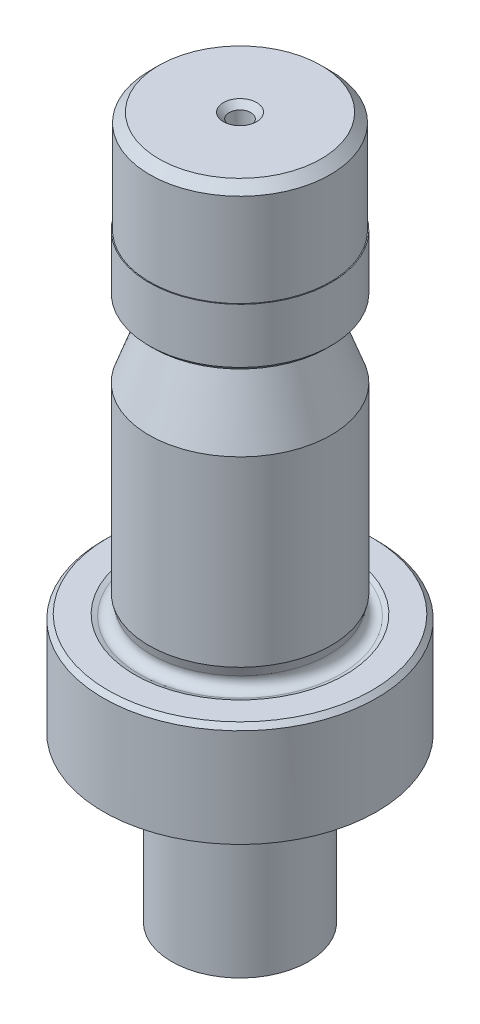
from build123d import *

# Parameters (mm, degrees)
FURO_DE_DI_METRO_3_32_0_09375_2_D           = 2.38125
FURO_DE_DI_METRO_3_32_0_09375_2_DEPTH       = 3
FURO_DE_DI_METRO_3_32_0_09375_2_CSINK_D     = 3.65125
FURO_DE_DI_METRO_3_32_0_09375_2_CSINK_ANGLE = 90
FURO_DE_DI_METRO_3_32_0_09375_2_TIP         = 0.715399675
ESBO_O10_OUTSIDE_W                          = 49.582
ESBO_O10_OUTSIDE_H                          = 49.582
ESBO_O10_OUTSIDE_R                          = 7.5
CORTE_EXTRUS_O2_DEPTH                       = 18
FILETE1_R                                   = 3


with BuildPart() as part:
    # Esboço1 → Revolução1 (revolve)
    with BuildSketch(Plane.XY):
        with BuildLine():
            Line((0, 77), (8.9, 77))
            Line((8.9, 77), (9.9, 76))
            Line((9.9, 76), (9.9, 65.8))
            Line((9.9, 65.8), (10, 65.8))
            Line((10, 65.8), (10, 59.8))
            Line((10, 59.8), (9.5, 59.3))
            Line((9.5, 59.3), (8.516386133, 59.3))
            ThreePointArc((8.516386133, 59.3), (7.697234088, 58.873576436), (7.576693512, 57.957979857))
            Line((7.576693512, 57.957979857), (10, 51.3))
            Line((10, 51.3), (10, 31.3))
            Line((10, 31.3), (9.732050808, 30.3))
            ThreePointArc((9.732050808, 30.3), (10.029032337, 29.297868418), (11.05681259, 29.107780314))
            Line((11.05681259, 29.107780314), (11.55681259, 29.3))
            Line((11.55681259, 29.3), (14.5, 29.3))
            Line((14.5, 29.3), (15, 28.8))
            Line((15, 28.8), (15, 0))
            Line((15, 0), (0, 0))
            Line((0, 0), (0, 77))
        make_face()
    revolve(axis=Axis((0, 77, 0), (0, -1, 0)))

    # Furo de diâmetro 3/32 (0.09375)2
    with Locations(Plane(origin=(0, 77, 0), x_dir=(-1, 0, 0), z_dir=(0, 1, 0))):
        with Locations((0, 0)):
            CounterSinkHole(FURO_DE_DI_METRO_3_32_0_09375_2_D / 2, FURO_DE_DI_METRO_3_32_0_09375_2_CSINK_D / 2, depth=FURO_DE_DI_METRO_3_32_0_09375_2_DEPTH, counter_sink_angle=FURO_DE_DI_METRO_3_32_0_09375_2_CSINK_ANGLE)
            with Locations((0, 0, -(FURO_DE_DI_METRO_3_32_0_09375_2_DEPTH + FURO_DE_DI_METRO_3_32_0_09375_2_TIP / 2))):  # 118° drill point
                Cone(0, FURO_DE_DI_METRO_3_32_0_09375_2_D / 2, FURO_DE_DI_METRO_3_32_0_09375_2_TIP, mode=Mode.SUBTRACT)

    # Esboço10 outside → Corte-extrusão2 (cut)
    with BuildSketch(Plane.XZ):
        Rectangle(ESBO_O10_OUTSIDE_W, ESBO_O10_OUTSIDE_H)
        Circle(ESBO_O10_OUTSIDE_R, mode=Mode.SUBTRACT)
    extrude(amount=-CORTE_EXTRUS_O2_DEPTH, mode=Mode.SUBTRACT)

    # Filete1
    filete1_edges = [part.edges().sort_by_distance(p)[0] for p in [
        (-7.5, 18, 0),
    ]]
    fillet(filete1_edges, radius=FILETE1_R)


solid = part.part
